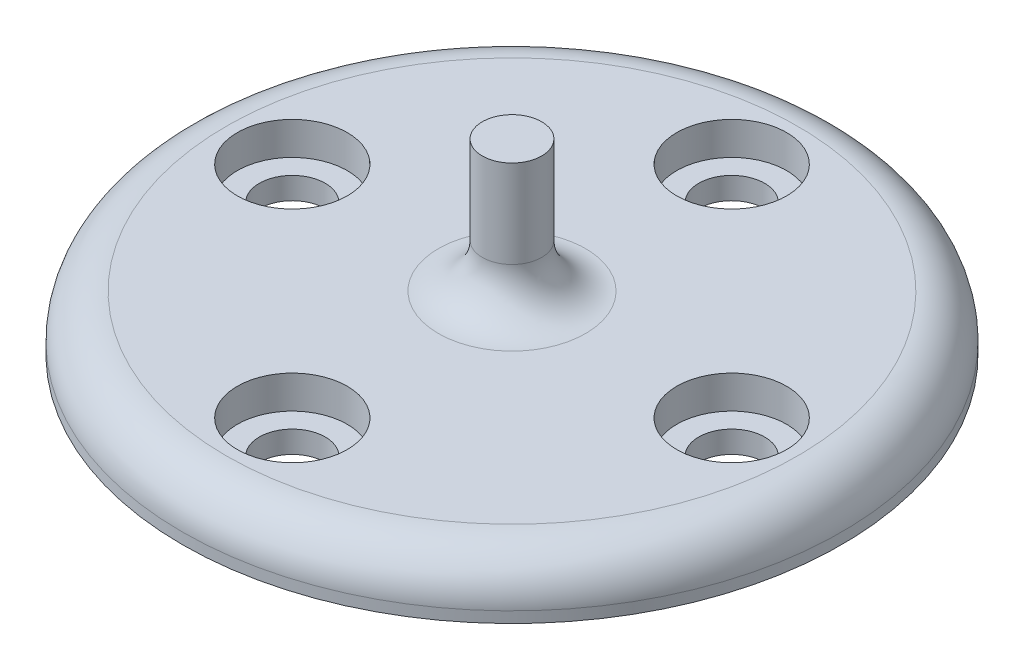
from build123d import *

# Parameters (mm, degrees)
SKETCH1_R           = 15
BOSS_EXTRUDE1_DEPTH = 2.5
SKETCH2_R           = 1.5
CUT_EXTRUDE1_DEPTH  = 3.5
SKETCH4_R           = 2.5
CUT_EXTRUDE2_DEPTH  = 1.5
CIRPATTERN1_COUNT   = 4
SKETCH3_R           = 1.35
BOSS_EXTRUDE2_DEPTH = 6
FILLET2_R           = 2
FILLET3_R           = 2


with BuildPart() as part:
    # Sketch1 → Boss-Extrude1 (new body)
    with BuildSketch(Plane(origin=(0, 0, 0), x_dir=(1, 0, 0), z_dir=(0, 1, 0))):
        Circle(SKETCH1_R)
    extrude(amount=BOSS_EXTRUDE1_DEPTH)

    # Sketch2 → Cut-Extrude1 (cut, through all)
    with BuildSketch(Plane(origin=(0, 2.5, 0), x_dir=(1, 0, 0), z_dir=(0, 1, 0))):
        with Locations((0, 10)):
            Circle(SKETCH2_R)
    cut_extrude1 = extrude(amount=-CUT_EXTRUDE1_DEPTH, mode=Mode.SUBTRACT)

    # Sketch4 → Cut-Extrude2 (cut)
    with BuildSketch(Plane(origin=(0, 2.5, 0), x_dir=(1, 0, 0), z_dir=(0, 1, 0))):
        with Locations((0, 10)):
            Circle(SKETCH4_R)
    cut_extrude2 = extrude(amount=-CUT_EXTRUDE2_DEPTH, mode=Mode.SUBTRACT)

    # CirPattern1: Cut-Extrude1, Cut-Extrude2 ×4 about axis
    cirpattern1_axis = Axis((0, 0, 0), (0, 1, 0))
    for i in range(1, CIRPATTERN1_COUNT):
        add(cut_extrude1.rotate(cirpattern1_axis, i * 360 / CIRPATTERN1_COUNT), mode=Mode.SUBTRACT)
        add(cut_extrude2.rotate(cirpattern1_axis, i * 360 / CIRPATTERN1_COUNT), mode=Mode.SUBTRACT)

    # Sketch3 → Boss-Extrude2 (add)
    with BuildSketch(Plane(origin=(0, 2.5, 0), x_dir=(1, 0, 0), z_dir=(0, 1, 0))):
        Circle(SKETCH3_R)
    extrude(amount=BOSS_EXTRUDE2_DEPTH)

    # Fillet2
    fillet2_edges = [part.edges().sort_by_distance(p)[0] for p in [
        (-1.35, 2.5, 0),
    ]]
    fillet(fillet2_edges, radius=FILLET2_R)

    # Fillet3
    fillet3_edges = [part.edges().sort_by_distance(p)[0] for p in [
        (-15, 2.5, 0),
    ]]
    fillet(fillet3_edges, radius=FILLET3_R)


solid = part.part
